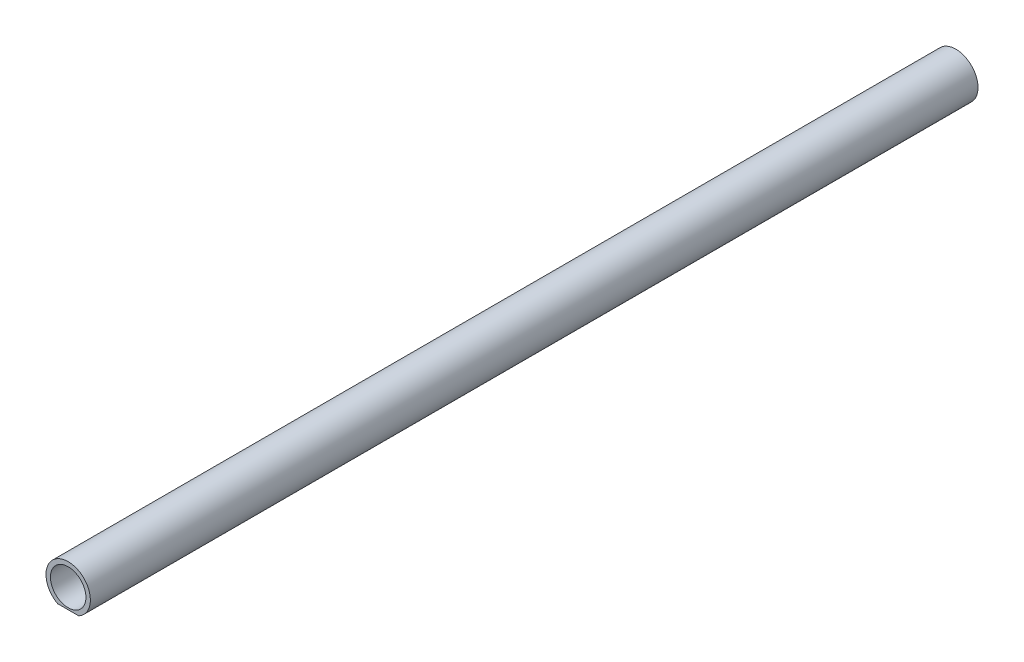
from build123d import *

# Parameters (mm, degrees)
SKETCH1_R           = 20
BOSS_EXTRUDE1_DEPTH = 1000


with BuildPart() as part:
    # Sketch1 → Boss-Extrude1 (new body)
    with BuildSketch(Plane.XY):
        with BuildLine():
            Line((-11.874342087, -15.661863664), (11.874342087, -15.661863664))
            ThreePointArc((11.874342087, -15.661863664), (0, 31.338136336), (-11.874342087, -15.661863664))
        make_face()
        with Locations((0, 6.338136336)):
            Circle(SKETCH1_R, mode=Mode.SUBTRACT)
    extrude(amount=BOSS_EXTRUDE1_DEPTH)


solid = part.part
